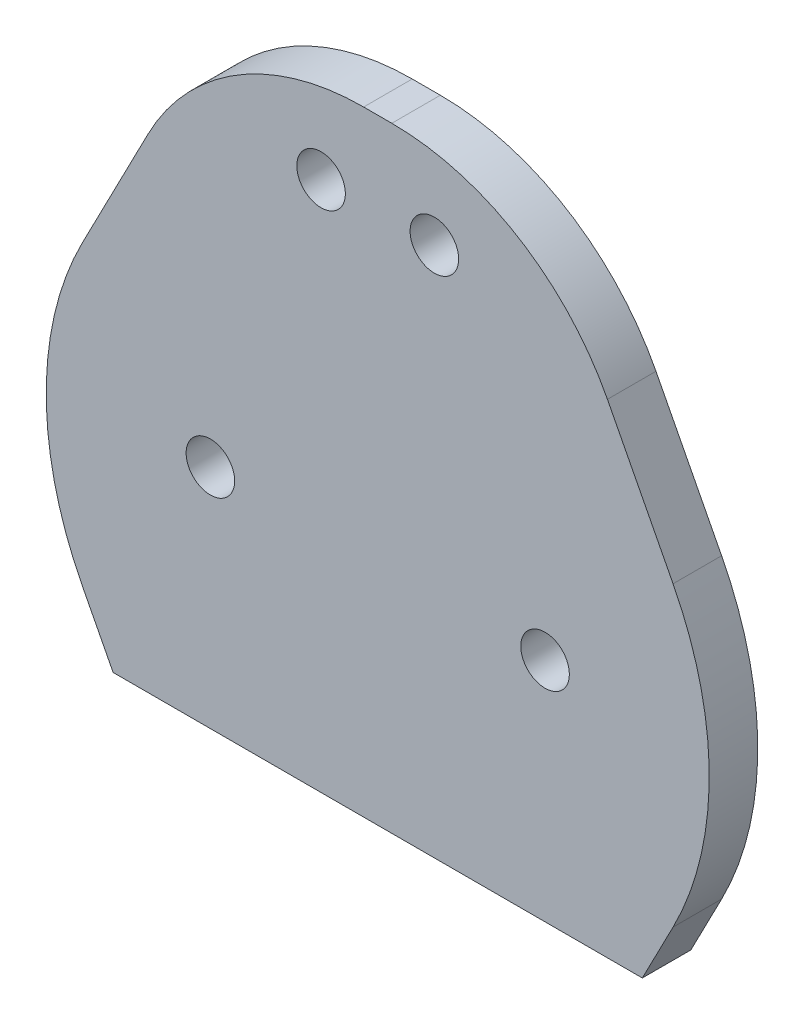
from build123d import *

# Parameters (mm, degrees)
SCHIZZO1_W                   = 46
SCHIZZO1_H                   = 38
SCHIZZO1_R                   = 1.5
ESTRUSIONE_ESTRUSIONE3_DEPTH = 3
TAGLIO_ESTRUSIONE1_DEPTH     = 3
RACCORDO1_R                  = 15
RACCORDO2_R                  = 15
RACCORDO3_R                  = 20
RACCORDO4_R                  = 20


with BuildPart() as part:
    # Schizzo1 → Estrusione-Estrusione3 (new body)
    with BuildSketch(Plane.XY):
        with Locations((-10.340402867, 5)):
            Rectangle(SCHIZZO1_W, SCHIZZO1_H)
        with Locations((-6.840402867, 18.793852416)):
            Circle(SCHIZZO1_R, mode=Mode.SUBTRACT)
        Circle(SCHIZZO1_R, mode=Mode.SUBTRACT)
        with Locations((-20.680805733, 0)):
            Circle(SCHIZZO1_R, mode=Mode.SUBTRACT)
        with Locations((-13.840402867, 18.793852416)):
            Circle(SCHIZZO1_R, mode=Mode.SUBTRACT)
    extrude(amount=ESTRUSIONE_ESTRUSIONE3_DEPTH)

    # Schizzo4 → Taglio-Estrusione1 (cut)
    with BuildSketch(Plane.XY.offset(3)):
        Polygon((-33.340402867, -1.13961018), (-20.340402867, 24), (-33.340402867, 24), align=None)
        Polygon((12.659597133, 24), (-0.340402867, 24), (12.659597133, -1.13961018), align=None)
        Polygon((-26.690137947, -14), (-33.340402867, -1.13961018), (-33.340402867, -14), align=None)
        Polygon((12.659597133, -14), (12.659597133, -1.13961018), (6.009332214, -14), align=None)
    extrude(amount=-TAGLIO_ESTRUSIONE1_DEPTH, mode=Mode.SUBTRACT)

    # Raccordo1
    raccordo1_edges = [part.edges().sort_by_distance(p)[0] for p in [
        (-0.340402867, 24, 1.5),
    ]]
    fillet(raccordo1_edges, radius=RACCORDO1_R)

    # Raccordo2
    raccordo2_edges = [part.edges().sort_by_distance(p)[0] for p in [
        (-20.340402867, 24, 1.5),
    ]]
    fillet(raccordo2_edges, radius=RACCORDO2_R)

    # Raccordo3
    raccordo3_edges = [part.edges().sort_by_distance(p)[0] for p in [
        (12.659597133, -1.13961018, 1.5),
    ]]
    fillet(raccordo3_edges, radius=RACCORDO3_R)

    # Raccordo4
    raccordo4_edges = [part.edges().sort_by_distance(p)[0] for p in [
        (-33.340402867, -1.13961018, 1.5),
    ]]
    fillet(raccordo4_edges, radius=RACCORDO4_R)


solid = part.part
